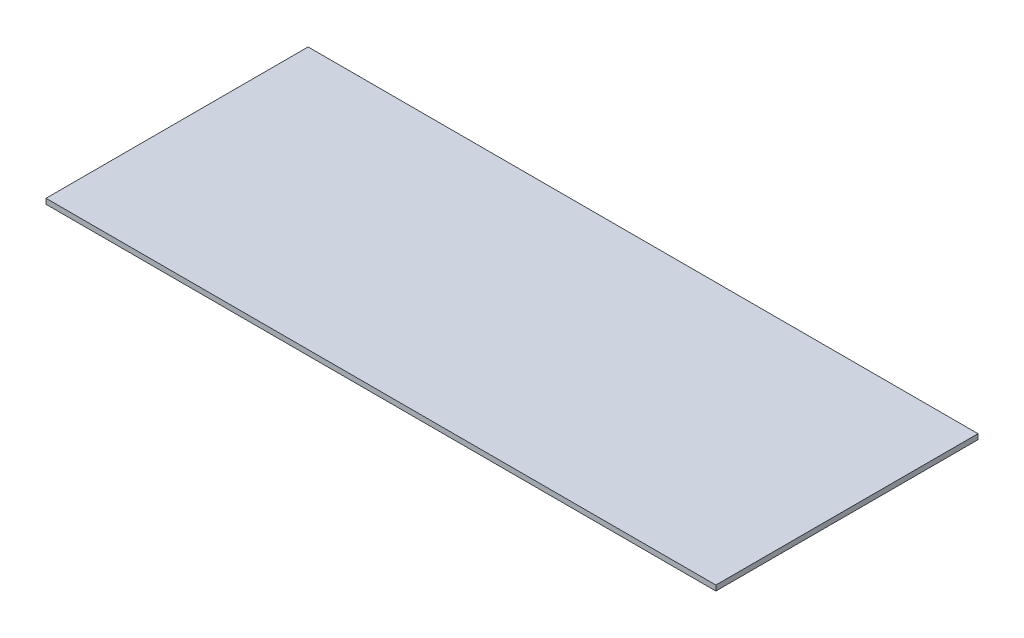
from build123d import *

# Parameters (mm, degrees)
SKETCH1_W           = 2300
SKETCH1_H           = 900
BOSS_EXTRUDE1_DEPTH = 18


with BuildPart() as part:
    # Sketch1 → Boss-Extrude1 (new body)
    with BuildSketch(Plane(origin=(0, 0, 0), x_dir=(1, 0, 0), z_dir=(0, 1, 0))):
        with Locations((1150, 450)):
            Rectangle(SKETCH1_W, SKETCH1_H)
    extrude(amount=BOSS_EXTRUDE1_DEPTH)


solid = part.part
